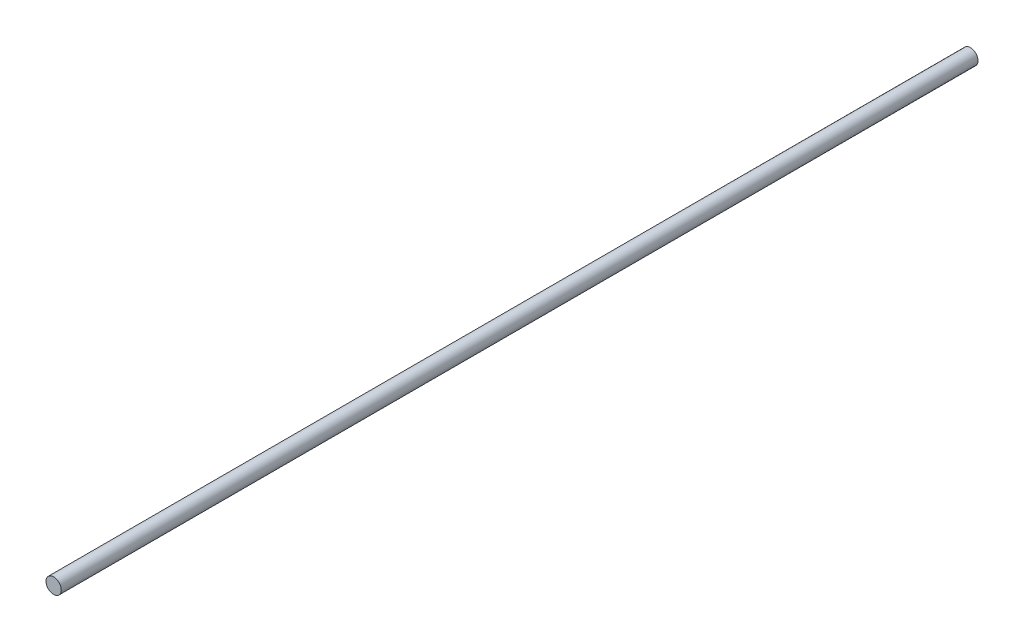
from build123d import *

# Parameters (mm, degrees)
SKETCH1_R           = 3.96875
BOSS_EXTRUDE1_DEPTH = 476.25


with BuildPart() as part:
    # Sketch1 → Boss-Extrude1 (new body)
    with BuildSketch(Plane.XY):
        Circle(SKETCH1_R)
    extrude(amount=BOSS_EXTRUDE1_DEPTH)


solid = part.part
